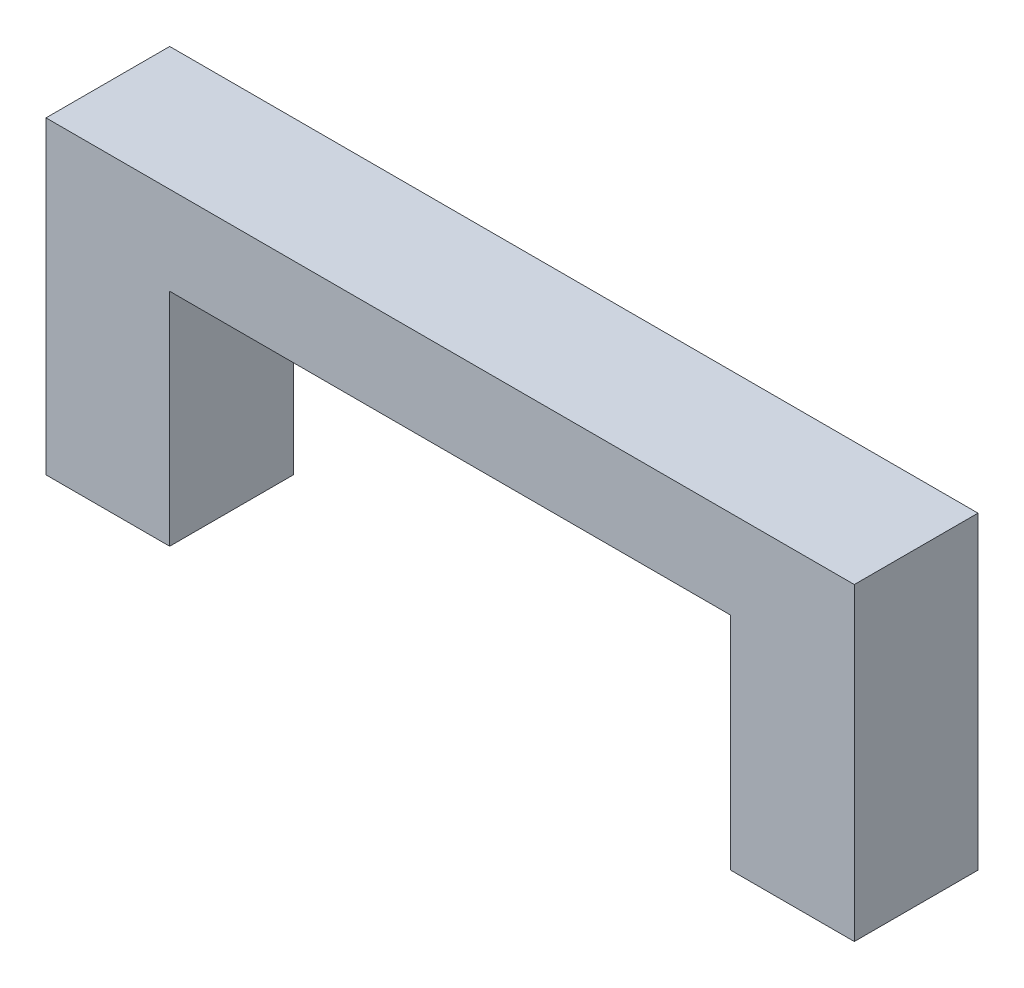
from build123d import *

# Parameters (mm, degrees)
BOSS_EXTRUDE1_DEPTH = 2.8
SKETCH2_W           = 2
SKETCH2_H           = 2
CUT_EXTRUDE1_DEPTH  = 2.2


with BuildPart() as part:
    # Sketch1 → Boss-Extrude1 (new body)
    with BuildSketch(Plane.XY):
        Polygon((0, 0), (0, 7), (18.3, 7), (18.3, 0), (15.5, 0), (15.5, 5), (2.8, 5), (2.8, 0), align=None)
    extrude(amount=BOSS_EXTRUDE1_DEPTH)

    # Sketch2 → Cut-Extrude1 (cut)
    with BuildSketch(Plane.XZ):
        with Locations((16.9, 1.4)):
            Rectangle(SKETCH2_W, SKETCH2_H)
        with Locations((1.4, 1.4)):
            Rectangle(SKETCH2_W, SKETCH2_H)
    extrude(amount=-CUT_EXTRUDE1_DEPTH, mode=Mode.SUBTRACT)


solid = part.part
